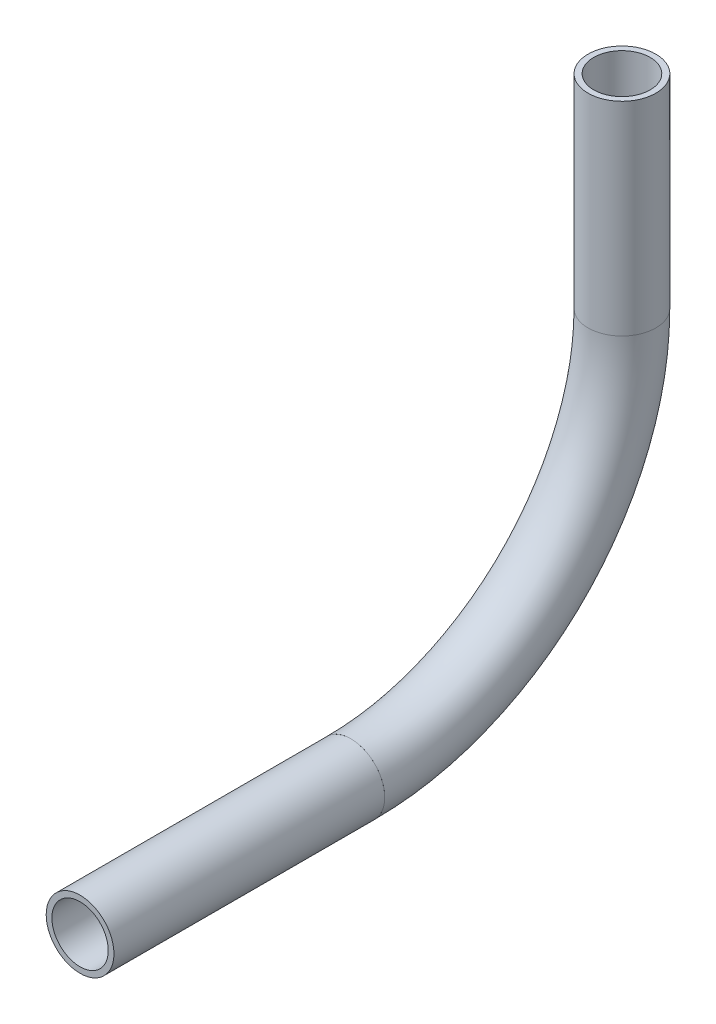
from build123d import *

# Parameters (mm, degrees)
SKETCH1_R                 = 6.35
SKETCH1_R_2               = 5.2832
PIPE_0_5_SCH_40_1_DEPTH   = 38.1
SKETCH1_ON_SEGMENT_2_R    = 6.35
SKETCH1_ON_SEGMENT_2_R_2  = 5.2832
PIPE_0_5_SCH_40_1_2_ANGLE = 90
SKETCH1_ON_SEGMENT_3_R    = 6.35
SKETCH1_ON_SEGMENT_3_R_2  = 5.2832
PIPE_0_5_SCH_40_1_3_DEPTH = 50.748068919


with BuildPart() as part:
    # Sketch1 → Pipe 0.5 SCH 40(1) (new body)
    with BuildSketch(Plane(origin=(0, -187.680467918, 259.179579455), x_dir=(0, 0, -1), z_dir=(0, -1, 0))):
        Circle(SKETCH1_R)
        Circle(SKETCH1_R_2, mode=Mode.SUBTRACT)
    extrude(amount=PIPE_0_5_SCH_40_1_DEPTH)


with BuildPart() as body_2:
    # Sketch1 on segment 2 (carried to the start of arc 2) → Pipe 0.5 SCH 40_1 2 (revolve)
    with BuildSketch(Plane(origin=(0, -225.780467918, 259.179579455), x_dir=(0, 0, -1), z_dir=(0, -1, 0))):
        Circle(SKETCH1_ON_SEGMENT_2_R)
        Circle(SKETCH1_ON_SEGMENT_2_R_2, mode=Mode.SUBTRACT)
    revolve(axis=Axis((0, -225.780467918, 309.979579455), (-1, 0, 0)), revolution_arc=PIPE_0_5_SCH_40_1_2_ANGLE)


with BuildPart() as body_3:
    # Sketch1 on segment 3 (carried to segment 3) → Pipe 0.5 SCH 40_1 3 (new body)
    with BuildSketch(Plane(origin=(0, -276.580467918, 309.979579455), x_dir=(0, -1, 0), z_dir=(0, 0, 1))):
        Circle(SKETCH1_ON_SEGMENT_3_R)
        Circle(SKETCH1_ON_SEGMENT_3_R_2, mode=Mode.SUBTRACT)
    extrude(amount=PIPE_0_5_SCH_40_1_3_DEPTH)


solid = Compound([part.part, body_2.part, body_3.part])
